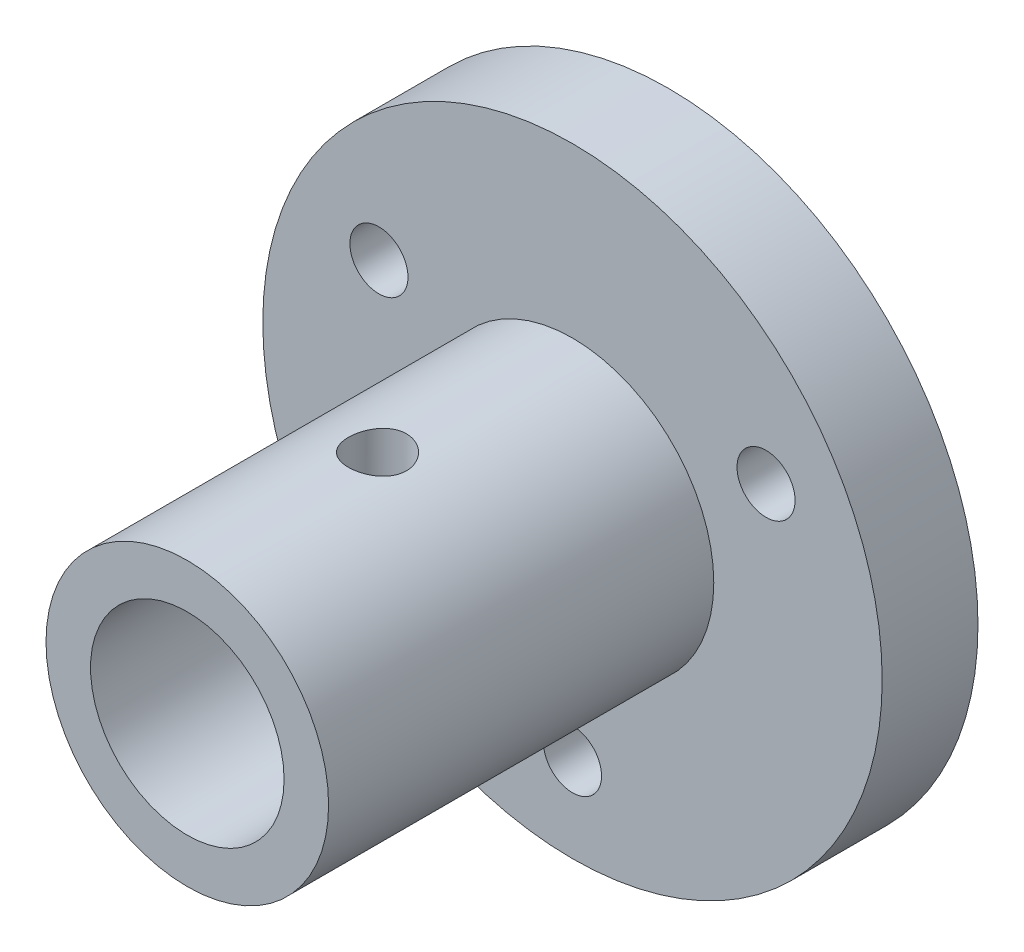
from build123d import *

# Parameters (mm, degrees)
SKETCH1_R               = 32
SKETCH1_R_2             = 3
BOSS_EXTRUDE1_DEPTH     = 9.9
SKETCH2_R               = 14.6
SKETCH2_R_2             = 10
BOSS_EXTRUDE2_DEPTH     = 39.8
SKETCH3_R               = 3
CUT_EXTRUDE1_DEPTH      = 33
CUT_EXTRUDE1_DEPTH_BACK = 33


with BuildPart() as part:
    # Sketch1 → Boss-Extrude1 (new body)
    with BuildSketch(Plane.XY):
        Circle(SKETCH1_R)
        with Locations((20, 11.547005384)):
            Circle(SKETCH1_R_2, mode=Mode.SUBTRACT)
        with Locations((0, -23.094010768)):
            Circle(SKETCH1_R_2, mode=Mode.SUBTRACT)
        with Locations((-20, 11.547005384)):
            Circle(SKETCH1_R_2, mode=Mode.SUBTRACT)
    extrude(amount=BOSS_EXTRUDE1_DEPTH)

    # Sketch2 → Boss-Extrude2 (add)
    with BuildSketch(Plane.XY.offset(9.9)):
        Circle(SKETCH2_R)
        Circle(SKETCH2_R_2, mode=Mode.SUBTRACT)
    extrude(amount=BOSS_EXTRUDE2_DEPTH)

    # Sketch3 → Cut-Extrude1 (cut, two sides)
    with BuildSketch(Plane(origin=(0, 0, 0), x_dir=(1, 0, 0), z_dir=(0, 1, 0))) as cut_extrude1_sk:
        with Locations((0, -30.05)):
            Circle(SKETCH3_R)
    extrude(amount=CUT_EXTRUDE1_DEPTH, mode=Mode.SUBTRACT)
    extrude(cut_extrude1_sk.sketch, amount=-CUT_EXTRUDE1_DEPTH_BACK, mode=Mode.SUBTRACT)


solid = part.part
